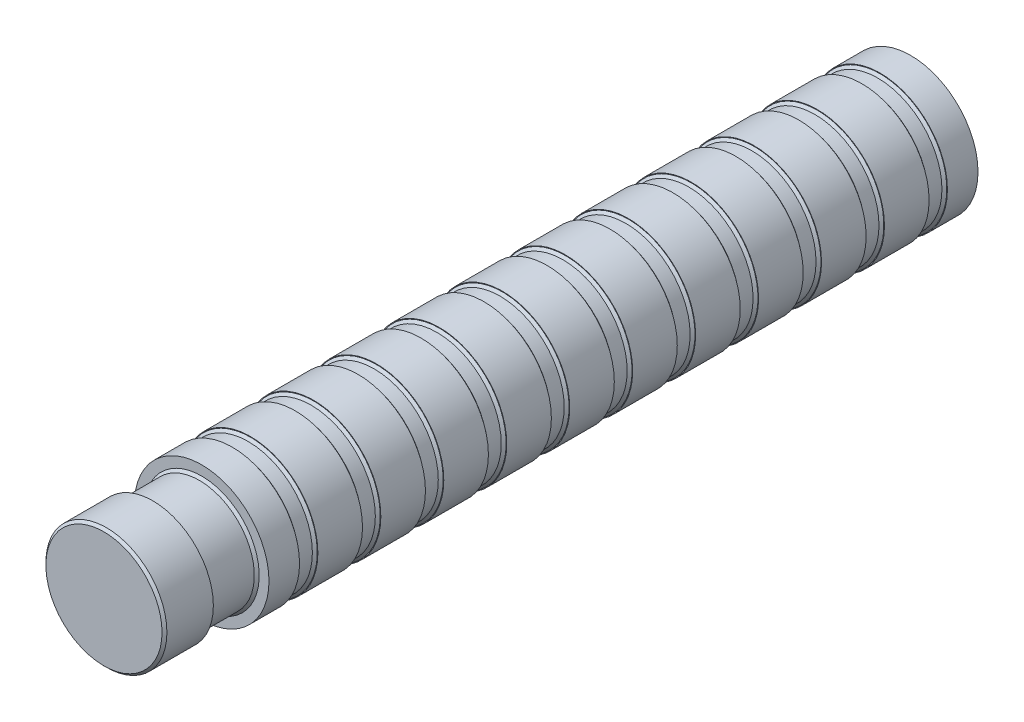
from build123d import *

# Parameters (mm, degrees)
CUT_EXTRUDE1_DEPTH  = 14
SKETCH5_R           = 4.5
BOSS_EXTRUDE1_DEPTH = 4
SKETCH6_R           = 4.95
BOSS_EXTRUDE2_DEPTH = 4
CHAMFER1_SIZE       = 0.2


with BuildPart() as part:
    # Sketch2 → Revolve2 (revolve)
    with BuildSketch(Plane(origin=(0, 0, 0), x_dir=(0, 0, -1), z_dir=(1, 0, 0))):
        Polygon((-29, 0), (29, 0), (29, 5.5), (26.5, 5.5), (26.5, 5.25), (25, 5.25), (25, 5.5), (21.35, 5.5), (21.35, 5.25), (19.85, 5.25), (19.85, 5.5), (16.2, 5.5), (16.2, 5.25), (14.7, 5.25), (14.7, 5.5), (11.05, 5.5), (11.05, 5.25), (9.55, 5.25), (9.55, 5.5), (5.9, 5.5), (5.9, 5.25), (4.4, 5.25), (4.4, 5.5), (0.75, 5.5), (0.75, 5.25), (-0.75, 5.25), (-0.75, 5.5), (-4.4, 5.5), (-4.4, 5.25), (-5.9, 5.25), (-5.9, 5.5), (-9.55, 5.5), (-9.55, 5.25), (-11.05, 5.25), (-11.05, 5.5), (-14.7, 5.5), (-14.7, 5.25), (-16.2, 5.25), (-16.2, 5.5), (-19.85, 5.5), (-19.85, 5.25), (-21.35, 5.25), (-21.35, 5.5), (-25, 5.5), (-25, 5.25), (-26.5, 5.25), (-26.5, 5.5), (-29, 5.5), align=None)
    revolve(axis=Axis((0, 0, -29), (0, 0, -1)))

    # Sketch3 → Cut-Extrude1 (cut)
    with BuildSketch(Plane(origin=(0, 0, -29), x_dir=(-1, 0, 0), z_dir=(0, 0, -1))):
        with BuildLine():
            Line((1.475, 1.529705854), (1.475, -1.529705854))
            ThreePointArc((1.475, -1.529705854), (-2.125, 0), (1.475, 1.529705854))
        make_face()
    extrude(amount=-CUT_EXTRUDE1_DEPTH, mode=Mode.SUBTRACT)

    # Sketch5 → Boss-Extrude1 (add)
    with BuildSketch(Plane.XY.offset(29)):
        Circle(SKETCH5_R)
    extrude(amount=BOSS_EXTRUDE1_DEPTH)

    # Sketch6 → Boss-Extrude2 (add)
    with BuildSketch(Plane.XY.offset(33)):
        Circle(SKETCH6_R)
    extrude(amount=BOSS_EXTRUDE2_DEPTH)

    # Chamfer1
    chamfer1_edges = [part.edges().sort_by_distance(p)[0] for p in [
        (-4.5, 0, 29),
        (-4.5, 0, 33),
        (-4.95, 0, 37),
        (0, -5.25, -26.5),
        (0, -5.25, -25),
        (0, -5.25, -21.35),
        (0, -5.25, -19.85),
        (0, -5.25, -16.2),
        (0, -5.25, -14.7),
        (0, -5.25, -11.05),
        (0, -5.25, -9.55),
        (0, -5.25, -5.9),
        (0, -5.25, -4.4),
        (0, -5.25, -0.75),
        (0, -5.25, 0.75),
        (0, -5.25, 4.4),
        (0, -5.25, 5.9),
        (0, -5.25, 9.55),
        (0, -5.25, 11.05),
        (0, -5.25, 14.7),
        (0, -5.25, 16.2),
        (0, -5.25, 19.85),
        (0, -5.25, 21.35),
        (0, -5.25, 25),
        (0, -5.25, 26.5),
    ]]
    chamfer(chamfer1_edges, length=CHAMFER1_SIZE)


solid = part.part
